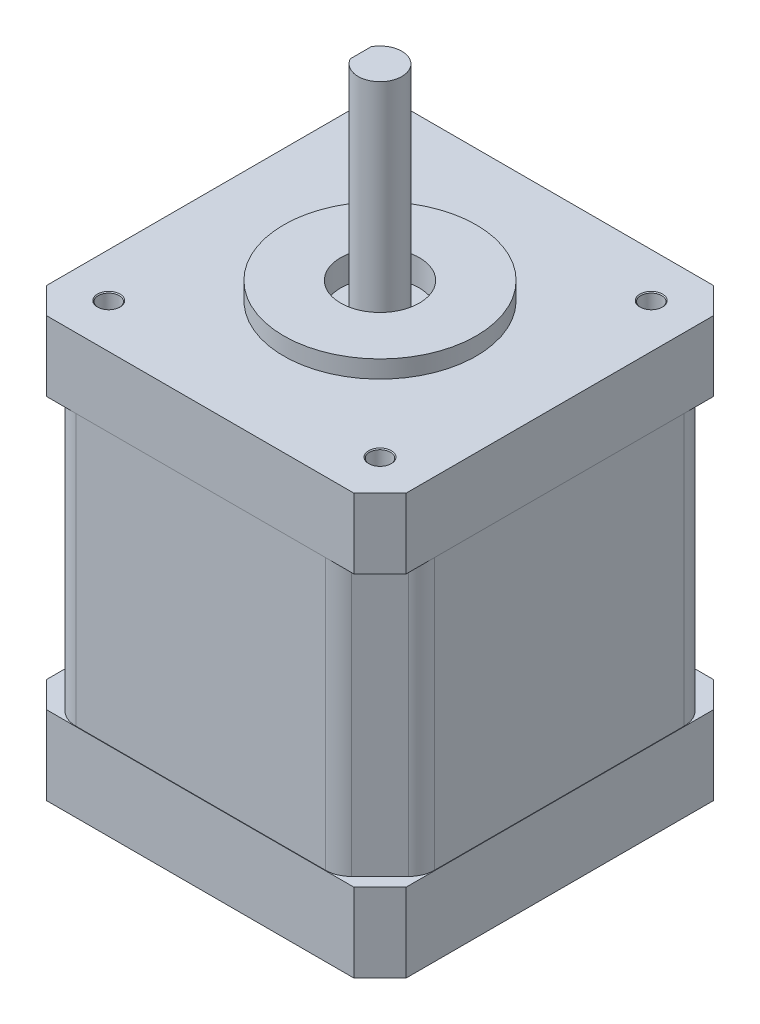
from build123d import *

# Parameters (mm, degrees)
CROQUIS1_W              = 41
CROQUIS1_H              = 41
SALIENTE_EXTRUIR1_DEPTH = 15.5
CHAFL_N1_SIZE           = 5
REDONDEO1_R             = 3
CROQUIS2_W              = 41.1
CROQUIS2_H              = 41.1
SALIENTE_EXTRUIR2_DEPTH = 8
CHAFL_N2_SIZE           = 3
SALIENTE_EXTRUIR3_DEPTH = 9
CROQUIS4_R              = 11
SALIENTE_EXTRUIR4_DEPTH = 2
CROQUIS5_R              = 1.190625
CORTAR_EXTRUIR1_DEPTH   = 3.175
CHAFL_N3_SIZE           = 0.1
CROQUIS6_R              = 4.7625
CROQUIS6_R_2            = 3.175
CORTAR_EXTRUIR2_DEPTH   = 3
C_PULA1_FACE_RADIUS     = 3.175
C_PULA1_HEIGHT          = 3
C_PULA2_FACE_RADIUS     = 3.175
C_PULA2_HEIGHT          = 3
C_PULA3_FACE_RADIUS     = 3.175
C_PULA3_HEIGHT          = 3
C_PULA4_FACE_RADIUS     = 3.175
C_PULA4_HEIGHT          = 3
CROQUIS7_R              = 4.5
CORTAR_EXTRUIR3_DEPTH   = 3
SALIENTE_EXTRUIR5_DEPTH = 24.43125
CORTAR_EXTRUIR4_DEPTH   = 20.5


with BuildPart() as part:
    # Croquis1 → Saliente-Extruir1 (new body, symmetric)
    with BuildSketch(Plane(origin=(0, 0, 0), x_dir=(1, 0, 0), z_dir=(0, 1, 0))):
        Rectangle(CROQUIS1_W, CROQUIS1_H)
    extrude(amount=SALIENTE_EXTRUIR1_DEPTH, both=True)

    # Chafl_n1
    chafl_n1_edges = [part.edges().sort_by_distance(p)[0] for p in [
        (20.5, 0, 20.5),
        (-20.5, 0, 20.5),
        (-20.5, 0, -20.5),
        (20.5, 0, -20.5),
    ]]
    chamfer(chafl_n1_edges, length=CHAFL_N1_SIZE)

    # Redondeo1
    redondeo1_edges = [part.edges().sort_by_distance(p)[0] for p in [
        (15.5, 0, 20.5),
        (-15.5, 0, 20.5),
        (-20.5, 0, -15.5),
        (-20.5, 0, 15.5),
        (15.5, 0, -20.5),
        (-15.5, 0, -20.5),
        (20.5, 0, 15.5),
        (20.5, 0, -15.5),
    ]]
    fillet(redondeo1_edges, radius=REDONDEO1_R)

    # Croquis2 → Saliente-Extruir2 (add)
    with BuildSketch(Plane(origin=(0, 15.5, 0), x_dir=(1, 0, 0), z_dir=(0, 1, 0))):
        Rectangle(CROQUIS2_W, CROQUIS2_H)
    extrude(amount=SALIENTE_EXTRUIR2_DEPTH)

    # Chafl_n2
    chafl_n2_edges = [part.edges().sort_by_distance(p)[0] for p in [
        (20.55, 19.5, 20.55),
        (20.55, 19.5, -20.55),
        (-20.55, 19.5, -20.55),
        (-20.55, 19.5, 20.55),
    ]]
    chamfer(chafl_n2_edges, length=CHAFL_N2_SIZE)

    # Croquis3 → Saliente-Extruir3 (add)
    with BuildSketch(Plane.XZ.offset(15.5)):
        Polygon((17.55, 20.55), (-17.55, 20.55), (-20.55, 17.55), (-20.55, -17.55), (-17.55, -20.55), (17.55, -20.55), (20.55, -17.55), (20.55, 17.55), align=None)
    extrude(amount=SALIENTE_EXTRUIR3_DEPTH)

    # Croquis4 → Saliente-Extruir4 (add)
    with BuildSketch(Plane(origin=(0, 23.5, 0), x_dir=(1, 0, 0), z_dir=(0, 1, 0))):
        Circle(CROQUIS4_R)
    extrude(amount=SALIENTE_EXTRUIR4_DEPTH)

    # Croquis5 → Cortar-Extruir1 (cut)
    with BuildSketch(Plane(origin=(0, 23.5, 0), x_dir=(1, 0, 0), z_dir=(0, 1, 0))):
        with Locations((-15.5, 15.5)):
            Circle(CROQUIS5_R)
        with Locations((15.5, 15.5)):
            Circle(CROQUIS5_R)
        with Locations((15.5, -15.5)):
            Circle(CROQUIS5_R)
        with Locations((-15.5, -15.5)):
            Circle(CROQUIS5_R)
    extrude(amount=-CORTAR_EXTRUIR1_DEPTH, mode=Mode.SUBTRACT)

    # Chafl_n3
    chafl_n3_edges = [part.edges().sort_by_distance(p)[0] for p in [
        (-16.690625, 23.5, -15.5),
        (14.309375, 23.5, -15.5),
        (14.309375, 23.5, 15.5),
        (-16.690625, 23.5, 15.5),
    ]]
    chamfer(chafl_n3_edges, length=CHAFL_N3_SIZE)

    # Croquis6 → Cortar-Extruir2 (cut)
    with BuildSketch(Plane.XZ.offset(24.5)):
        Circle(CROQUIS6_R)
        with Locations((-15.5, 15.5)):
            Circle(CROQUIS6_R_2)
        with Locations((15.5, 15.5)):
            Circle(CROQUIS6_R_2)
        with Locations((15.5, -15.5)):
            Circle(CROQUIS6_R_2)
        with Locations((-15.5, -15.5)):
            Circle(CROQUIS6_R_2)
    extrude(amount=-CORTAR_EXTRUIR2_DEPTH, mode=Mode.SUBTRACT)

    # C_pula1: a dome of height H over a round flat face of radius A is a cap of a sphere of radius (A * A + H * H) / (2 * H)
    c_pula1_r = (C_PULA1_FACE_RADIUS * C_PULA1_FACE_RADIUS + C_PULA1_HEIGHT * C_PULA1_HEIGHT) / (2 * C_PULA1_HEIGHT)
    c_pula1_base = Plane((15.5, -21.5, 15.5), z_dir=(0, -1, 0))
    with Locations(c_pula1_base.offset(C_PULA1_HEIGHT - c_pula1_r)):
        c_pula1_ball = Sphere(c_pula1_r, mode=Mode.PRIVATE)
    add(split(c_pula1_ball, bisect_by=c_pula1_base, keep=Keep.TOP, mode=Mode.PRIVATE))

    # C_pula2: a dome of height H over a round flat face of radius A is a cap of a sphere of radius (A * A + H * H) / (2 * H)
    c_pula2_r = (C_PULA2_FACE_RADIUS * C_PULA2_FACE_RADIUS + C_PULA2_HEIGHT * C_PULA2_HEIGHT) / (2 * C_PULA2_HEIGHT)
    c_pula2_base = Plane((-15.5, -21.5, 15.5), z_dir=(0, -1, 0))
    with Locations(c_pula2_base.offset(C_PULA2_HEIGHT - c_pula2_r)):
        c_pula2_ball = Sphere(c_pula2_r, mode=Mode.PRIVATE)
    add(split(c_pula2_ball, bisect_by=c_pula2_base, keep=Keep.TOP, mode=Mode.PRIVATE))

    # C_pula3: a dome of height H over a round flat face of radius A is a cap of a sphere of radius (A * A + H * H) / (2 * H)
    c_pula3_r = (C_PULA3_FACE_RADIUS * C_PULA3_FACE_RADIUS + C_PULA3_HEIGHT * C_PULA3_HEIGHT) / (2 * C_PULA3_HEIGHT)
    c_pula3_base = Plane((15.5, -21.5, -15.5), z_dir=(0, -1, 0))
    with Locations(c_pula3_base.offset(C_PULA3_HEIGHT - c_pula3_r)):
        c_pula3_ball = Sphere(c_pula3_r, mode=Mode.PRIVATE)
    add(split(c_pula3_ball, bisect_by=c_pula3_base, keep=Keep.TOP, mode=Mode.PRIVATE))

    # C_pula4: a dome of height H over a round flat face of radius A is a cap of a sphere of radius (A * A + H * H) / (2 * H)
    c_pula4_r = (C_PULA4_FACE_RADIUS * C_PULA4_FACE_RADIUS + C_PULA4_HEIGHT * C_PULA4_HEIGHT) / (2 * C_PULA4_HEIGHT)
    c_pula4_base = Plane((-15.5, -21.5, -15.5), z_dir=(0, -1, 0))
    with Locations(c_pula4_base.offset(C_PULA4_HEIGHT - c_pula4_r)):
        c_pula4_ball = Sphere(c_pula4_r, mode=Mode.PRIVATE)
    add(split(c_pula4_ball, bisect_by=c_pula4_base, keep=Keep.TOP, mode=Mode.PRIVATE))

    # Croquis7 → Cortar-Extruir3 (cut)
    with BuildSketch(Plane(origin=(0, 25.5, 0), x_dir=(1, 0, 0), z_dir=(0, 1, 0))):
        Circle(CROQUIS7_R)
    extrude(amount=-CORTAR_EXTRUIR3_DEPTH, mode=Mode.SUBTRACT)

    # Croquis8 → Saliente-Extruir5 (add)
    with BuildSketch(Plane(origin=(0, 22.5, 0), x_dir=(1, 0, 0), z_dir=(0, 1, 0))):
        with BuildLine():
            ThreePointArc((2.5, 0), (0.612372436, 2.423839929), (-2.2, 1.187434209))
            Line((-2.2, 1.187434209), (-2.2, -1.187434209))
            ThreePointArc((-2.2, -1.187434209), (0.612372436, -2.423839929), (2.5, 0))
        make_face()
        with BuildLine():
            Line((-2.2, -1.187434209), (-2.2, 1.187434209))
            ThreePointArc((-2.2, 1.187434209), (-2.5, 0), (-2.2, -1.187434209))
        make_face()
    extrude(amount=SALIENTE_EXTRUIR5_DEPTH)

    # Croquis9 → Cortar-Extruir4 (cut)
    with BuildSketch(Plane(origin=(0, 46.93125, 0), x_dir=(1, 0, 0), z_dir=(0, 1, 0))):
        with BuildLine():
            Line((-2.2, -1.187434209), (-2.2, 1.187434209))
            ThreePointArc((-2.2, 1.187434209), (-2.5, 0), (-2.2, -1.187434209))
        make_face()
    extrude(amount=-CORTAR_EXTRUIR4_DEPTH, mode=Mode.SUBTRACT)


solid = part.part
